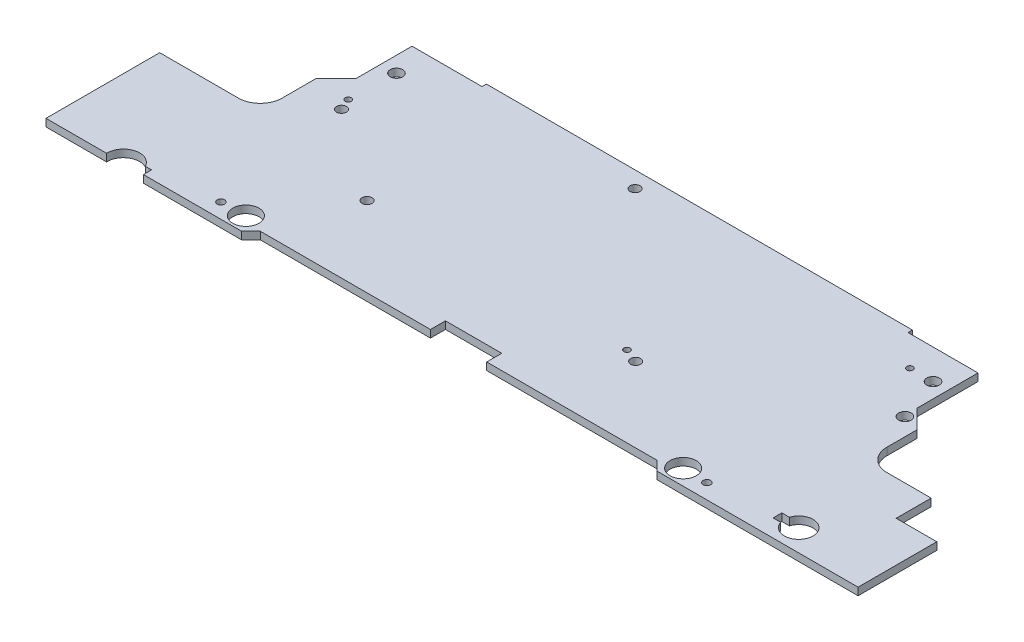
from build123d import *

# Parameters (mm, degrees)
BOSS_EXTRU_1_DEPTH      = 1.2
ESQUISSE1_4_R           = 2.1
ESQUISSE1_4_R_2         = 0.8
ESQUISSE1_4_R_3         = 1
ESQUISSE1_4_R_4         = 0.5
ESQUISSE1_4_R_5         = 0.6
ENL_V_MAT_EXTRU_1_DEPTH = 1.2


with BuildPart() as part:
    # Esquisse1 → Boss.-Extru.1 (new body)
    with BuildSketch(Plane(origin=(0, 0, 0), x_dir=(1, 0, 0), z_dir=(0, 1, 0))):
        with BuildLine():
            Line((-64.55, 14.3), (-64.55, -3.9))
            Line((-64.55, -3.9), (-54.85, -3.9))
            ThreePointArc((-54.85, -3.9), (-52.920836567, -1.286846787), (-49.95, -2.6))
            Line((-49.95, -2.6), (-48.95, -2.6))
            Line((-48.95, -2.6), (-48.95, -3.9))
            Line((-48.95, -3.9), (-33.25, -3.9))
            Line((-33.25, -3.9), (-31.75, -2.4))
            Line((-31.75, -2.4), (-4.5, -2.4))
            Line((-4.5, -2.4), (-4.5, 0))
            Line((-4.5, 0), (4.5, 0))
            Line((4.5, 0), (4.5, -2.4))
            Line((4.5, -2.4), (31.75, -2.4))
            Line((31.75, -2.4), (33.25, -3.9))
            Line((33.25, -3.9), (65.45, -3.9))
            Line((65.45, -3.9), (65.45, 8.7))
            Line((65.45, 8.7), (58.95, 8.7))
            Line((58.95, 8.7), (58.95, 14.3))
            Line((58.95, 14.3), (51.85, 14.3))
            ThreePointArc((51.85, 14.3), (49.375126266, 15.325126266), (48.35, 17.8))
            Line((48.35, 17.8), (48.35, 22.6))
            Line((48.35, 22.6), (45.35, 25.6))
            Line((45.35, 25.6), (45.35, 35.4))
            Line((45.35, 35.4), (34.15, 35.4))
            Line((34.15, 35.4), (34.15, 36.1))
            Line((34.15, 36.1), (-34.05, 36.1))
            Line((-34.05, 36.1), (-34.05, 35.4))
            Line((-34.05, 35.4), (-45.25, 35.4))
            Line((-45.25, 35.4), (-45.25, 26.4))
            Line((-45.25, 26.4), (-48.45, 23.2))
            Line((-48.45, 23.2), (-48.45, 17.8))
            ThreePointArc((-48.45, 17.8), (-49.475126266, 15.325126266), (-51.95, 14.3))
            Line((-51.95, 14.3), (-64.55, 14.3))
        make_face()
    extrude(amount=BOSS_EXTRU_1_DEPTH)

    # Esquisse1_4 → Enl_v. mat.-Extru.1 (cut)
    with BuildSketch(Plane(origin=(0, 0, 0), x_dir=(1, 0, 0), z_dir=(0, 1, 0))):
        with BuildLine():
            Line((49.05, -1.1), (50.25910977, -1.1))
            ThreePointArc((50.25910977, -1.1), (54.75, -0.4), (50.25910977, 0.3))
            Line((50.25910977, 0.3), (49.05, 0.3))
            Line((49.05, 0.3), (49.05, -1.1))
        make_face()
        with Locations((34.95, -1.4)):
            Circle(ESQUISSE1_4_R)
        with Locations((-35.05, -1.4)):
            Circle(ESQUISSE1_4_R)
        with Locations((-7.65, 33.5)):
            Circle(ESQUISSE1_4_R_2)
        with Locations((42.95, 30.6)):
            Circle(ESQUISSE1_4_R_3)
        with Locations((-27.45, 10.4)):
            Circle(ESQUISSE1_4_R_2)
        with Locations((16.35, 9.6)):
            Circle(ESQUISSE1_4_R_2)
        with Locations((-42.95, 22.9)):
            Circle(ESQUISSE1_4_R_4)
        with Locations((-42.75, 30.4)):
            Circle(ESQUISSE1_4_R_3)
        with Locations((45.55, 23.5)):
            Circle(ESQUISSE1_4_R_3)
        with Locations((14.05, 10.5)):
            Circle(ESQUISSE1_4_R_4)
        with Locations((-42.15, 21)):
            Circle(ESQUISSE1_4_R_2)
        with Locations((-38.95, -1.5)):
            Circle(ESQUISSE1_4_R_5)
        with Locations((39.25, 30.6)):
            Circle(ESQUISSE1_4_R_4)
        with Locations((38.85, -1.5)):
            Circle(ESQUISSE1_4_R_5)
    extrude(amount=ENL_V_MAT_EXTRU_1_DEPTH, mode=Mode.SUBTRACT)


solid = part.part
